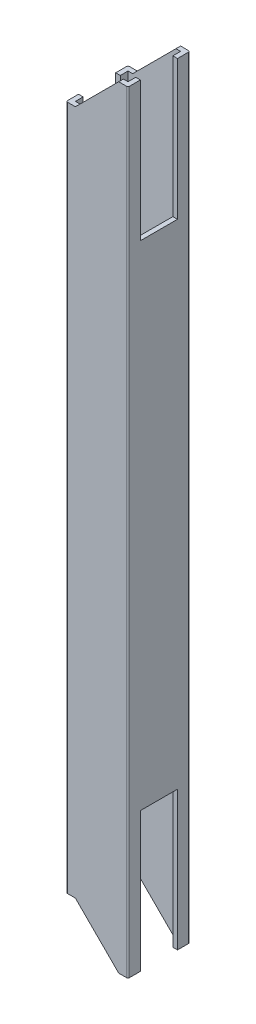
from build123d import *

# Parameters (mm, degrees)
SKETCH1_W           = 17
SKETCH1_H           = 17
BOSS_EXTRUDE1_DEPTH = 249.5
SKETCH2_W           = 12
SKETCH2_H           = 45
CUT_EXTRUDE1_DEPTH  = 252.098088404
CUT_EXTRUDE2_DEPTH  = 252.098088404


with BuildPart() as part:
    # Sketch1 → Boss-Extrude1 (new body)
    with BuildSketch(Plane(origin=(0, 0, 0), x_dir=(1, 0, 0), z_dir=(0, 1, 0))):
        with BuildLine():
            Line((0.5, 0), (19.5, 0))
            ThreePointArc((19.5, 0), (19.853553391, 0.146446609), (20, 0.5))
            Line((20, 0.5), (20, 19.5))
            ThreePointArc((20, 19.5), (19.853553391, 19.853553391), (19.5, 20))
            Line((19.5, 20), (0.5, 20))
            ThreePointArc((0.5, 20), (0.146446609, 19.853553391), (0, 19.5))
            Line((0, 19.5), (0, 0.5))
            ThreePointArc((0, 0.5), (0.146446609, 0.146446609), (0.5, 0))
        make_face()
        with Locations((10, 10)):
            Rectangle(SKETCH1_W, SKETCH1_H, mode=Mode.SUBTRACT)
    extrude(amount=BOSS_EXTRUDE1_DEPTH)

    # Sketch2 → Cut-Extrude1 (cut, through all)
    with BuildSketch(Plane.ZY):
        with Locations((-10, 22.5)):
            Rectangle(SKETCH2_W, SKETCH2_H)
        with Locations((-10, 227)):
            Rectangle(SKETCH2_W, SKETCH2_H)
    extrude(amount=-CUT_EXTRUDE1_DEPTH, mode=Mode.SUBTRACT)

    # Sketch3 → Cut-Extrude2 (cut, through all)
    with BuildSketch(Plane(origin=(0, 0, -20), x_dir=(-1, 0, 0), z_dir=(0, 0, -1))):
        Polygon((0, 235.5), (-3, 235.5), (-17, 249.5), (0, 249.5), align=None)
        Polygon((-17, 0), (0, 0), (0, 14), (-3, 14), align=None)
    extrude(amount=-CUT_EXTRUDE2_DEPTH, mode=Mode.SUBTRACT)


solid = part.part
